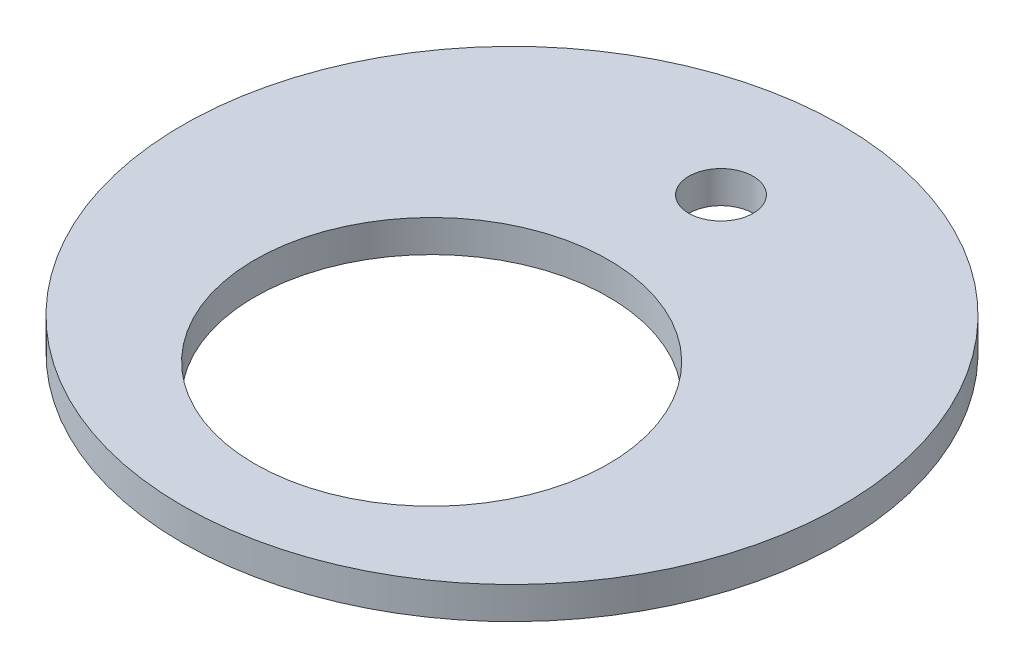
from build123d import *

# Parameters (mm, degrees)
SKETCH1_R           = 20.5
SKETCH1_R_2         = 11
SKETCH1_R_3         = 2
BOSS_EXTRUDE1_DEPTH = 2


with BuildPart() as part:
    # Sketch1 → Boss-Extrude1 (new body)
    with BuildSketch(Plane(origin=(0, 0, 0), x_dir=(1, 0, 0), z_dir=(0, 1, 0))):
        Circle(SKETCH1_R)
        with Locations((0, -5)):
            Circle(SKETCH1_R_2, mode=Mode.SUBTRACT)
        with Locations((0, 13)):
            Circle(SKETCH1_R_3, mode=Mode.SUBTRACT)
    extrude(amount=BOSS_EXTRUDE1_DEPTH)


solid = part.part
